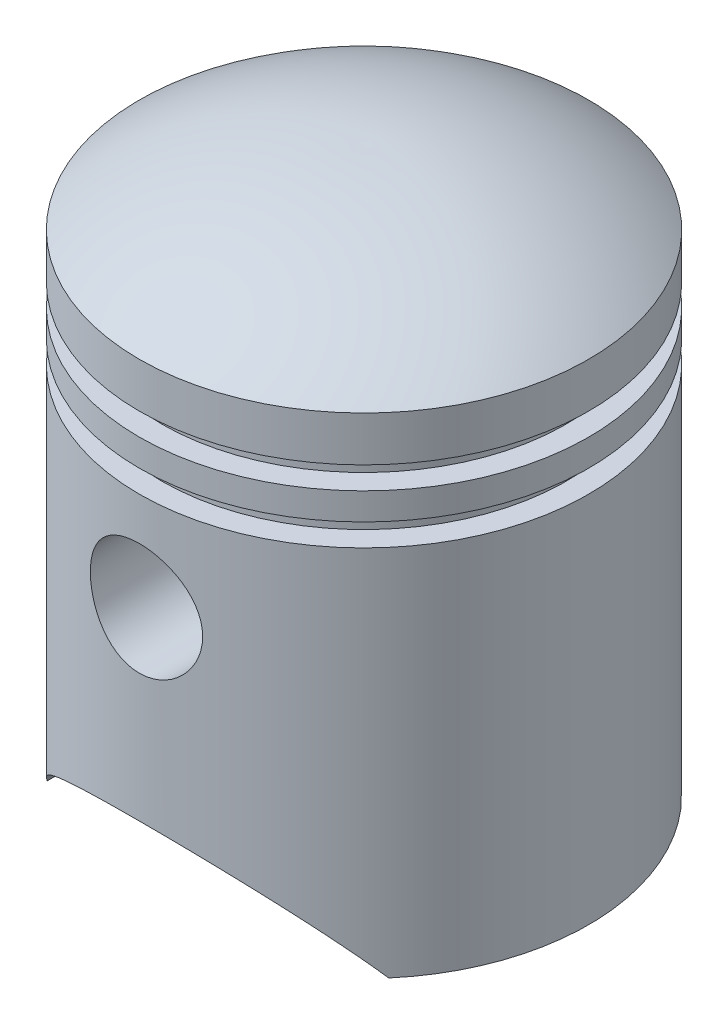
from build123d import *

# Parameters (mm, degrees)
SKETCH3_R               = 6.25
CUT_EXTRUDE2_DEPTH      = 26.0000001
CUT_EXTRUDE2_DEPTH_BACK = 26.0000001
BOSS_EXTRUDE1_START     = 12
SKETCH4_R               = 7.25
SKETCH4_R_2             = 6.25
BOSS_EXTRUDE1_DEPTH     = 11


with BuildPart() as part:
    # Sketch1 → Revolve2 (revolve)
    with BuildSketch(Plane.XY, mode=Mode.PRIVATE) as revolve2_sk:
        with BuildLine():
            Line((25, 0), (25, 41.5))
            Line((25, 41.5), (22.5, 41.5))
            Line((22.5, 41.5), (22.5, 44))
            Line((22.5, 44), (25, 44))
            Line((25, 44), (25, 47))
            Line((25, 47), (22.5, 47))
            Line((22.5, 47), (22.5, 49.5))
            Line((22.5, 49.5), (25, 49.5))
            Line((25, 49.5), (25, 54.5))
            ThreePointArc((25, 54.5), (13.174901691, 60.609067785), (0, 62.5))
            Line((0, 62.5), (0, 60.500605095))
            Line((0, 60.500605095), (0.04919363, 60.500605095))
            ThreePointArc((0.04919363, 60.500605095), (12.093024708, 58.851979987), (23, 53.484511145))
            Line((23, 53.484511145), (23, 51.5))
            Line((23, 51.5), (20.5, 51.5))
            Line((20.5, 51.5), (20.5, 45.5))
            Line((20.5, 45.5), (20.5, 39.5))
            Line((20.5, 39.5), (23, 39.5))
            Line((23, 39.5), (23, 0))
            Line((23, 0), (25, 0))
        make_face()
    revolve(revolve2_sk.sketch.rotate(Axis((0, 62.5, 0), (0, -1, 0)), 90), axis=Axis((0, 62.5, 0), (0, -1, 0)))  # turned: the seam where the file's is

    # Sketch3 → Cut-Extrude2 (cut, two sides)
    with BuildSketch(Plane.XY) as cut_extrude2_sk:
        with Locations((0, 30.5)):
            Circle(SKETCH3_R)
        with BuildLine():
            Line((-19, 0), (19, 0))
            ThreePointArc((19, 0), (0, 10), (-19, 0))
        make_face()
    extrude(amount=CUT_EXTRUDE2_DEPTH, mode=Mode.SUBTRACT)
    extrude(cut_extrude2_sk.sketch, amount=-CUT_EXTRUDE2_DEPTH_BACK, mode=Mode.SUBTRACT)

    # Sketch4 → Boss-Extrude1 (add)
    with BuildSketch(Plane.XY.offset(BOSS_EXTRUDE1_START)):
        with Locations(Location((0, 30.5, 0), (0, 0, 90))):  # turned: the seam where the file's is
            Circle(SKETCH4_R)
        with Locations((0, 30.5)):
            Circle(SKETCH4_R_2, mode=Mode.SUBTRACT)
    boss_extrude1 = extrude(amount=BOSS_EXTRUDE1_DEPTH)

    # Mirror1: Boss-Extrude1 across plane
    add(boss_extrude1.mirror(Plane.XY))


solid = part.part
